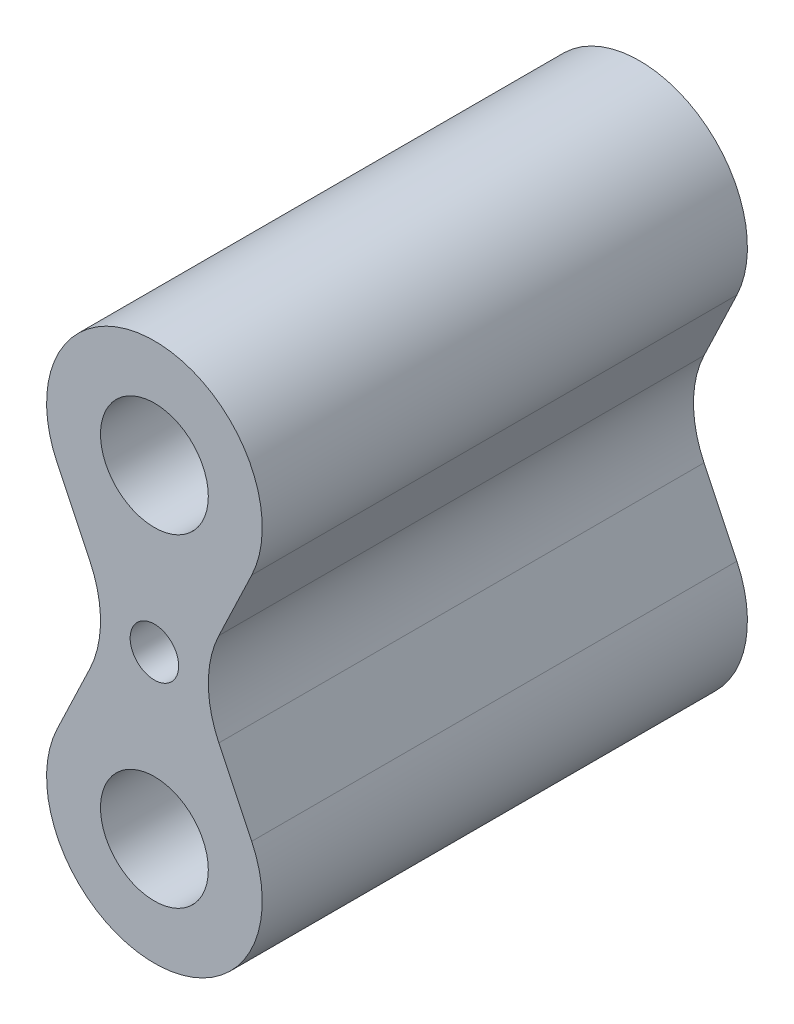
from build123d import *

# Parameters (mm, degrees)
SKETCH1_R              = 10
BOSS_EXTRUDE1_DEPTH    = 45
M10X1_0_TAPPED_HOLE1_D = 9


with BuildPart() as part:
    # Sketch1 → Boss-Extrude1 (new body, symmetric)
    with BuildSketch(Plane.XY):
        with BuildLine():
            Line((-18.047378541, 21.380711875), (-11.952621459, 8.619288125))
            ThreePointArc((-11.952621459, 8.619288125), (-10, 0), (-11.952621459, -8.619288125))
            Line((-11.952621459, -8.619288125), (-18.047378541, -21.380711875))
            ThreePointArc((-18.047378541, -21.380711875), (0, -50), (18.047378541, -21.380711875))
            Line((18.047378541, -21.380711875), (11.952621459, -8.619288125))
            ThreePointArc((11.952621459, -8.619288125), (10, 0), (11.952621459, 8.619288125))
            Line((11.952621459, 8.619288125), (18.047378541, 21.380711875))
            ThreePointArc((18.047378541, 21.380711875), (0, 50), (-18.047378541, 21.380711875))
        make_face()
        with Locations((0, 30)):
            Circle(SKETCH1_R, mode=Mode.SUBTRACT)
        with Locations((0, -30)):
            Circle(SKETCH1_R, mode=Mode.SUBTRACT)
    extrude(amount=BOSS_EXTRUDE1_DEPTH, both=True)

    # M10x1.0 Tapped Hole1 (through all)
    with Locations(Plane.XY.offset(45)):
        with Locations((0, 0)):
            Hole(M10X1_0_TAPPED_HOLE1_D / 2)


solid = part.part
